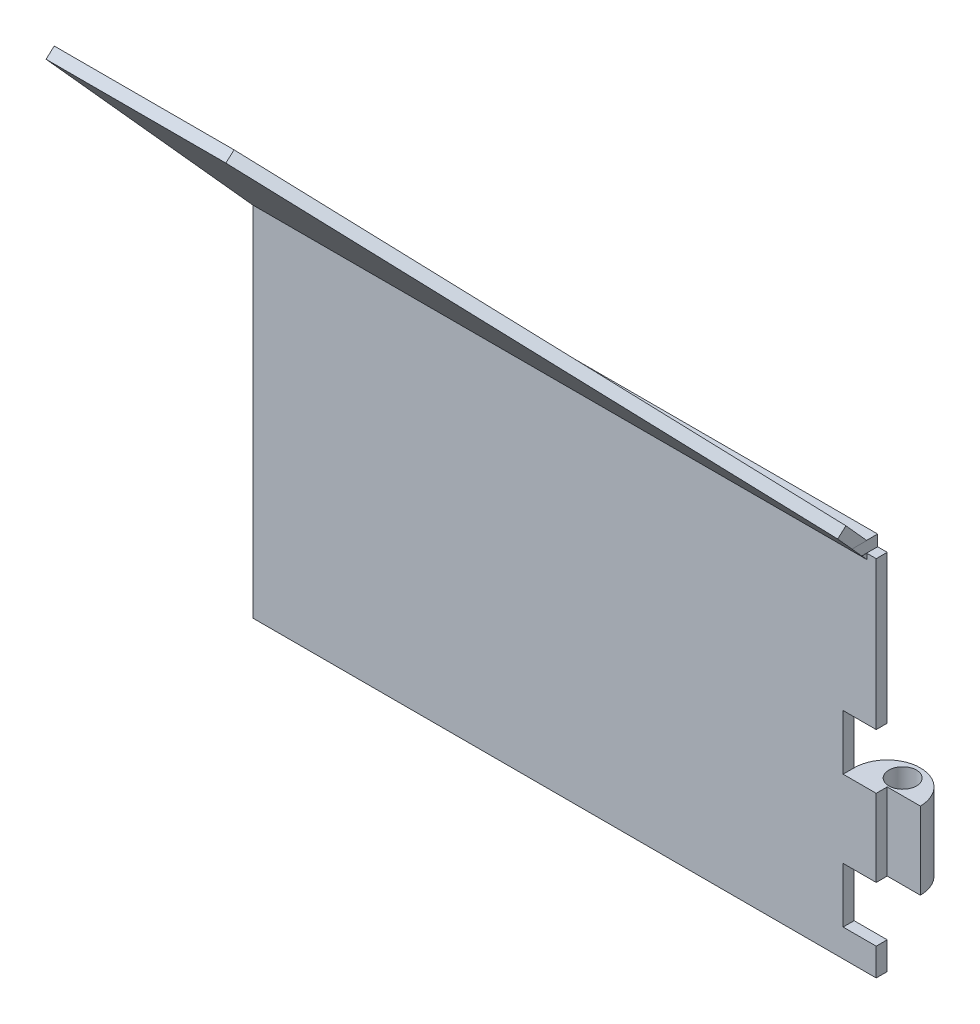
from build123d import *

# Parameters (mm, degrees)
BOSS_EXTRUDE1_DEPTH = 1
BOSS_EXTRUDE3_DEPTH = 50
BOSS_EXTRUDE6_DEPTH = 7
SKETCH8_R           = 1.25
CUT_EXTRUDE3_DEPTH  = 7
BOSS_EXTRUDE4_DEPTH = 1
SKETCH6_W           = 55.65
SKETCH6_H           = 1
BOSS_EXTRUDE5_DEPTH = 1.110613
SKETCH7_W           = 0.87
SKETCH7_H           = 1
CUT_EXTRUDE2_DEPTH  = 2.345633


with BuildPart() as part:
    # Sketch1 → Boss-Extrude1 (new body)
    with BuildSketch(Plane.XY):
        Polygon((-28.25, -16.96), (-28.25, 16.96), (28.25, 16.96), (28.25, 2.54), (25.25, 2.54), (25.25, -2.46), (28.25, -2.46), (28.25, -9.46), (25.25, -9.46), (25.25, -14.46), (28.25, -14.46), (28.25, -16.96), align=None)
    extrude(amount=BOSS_EXTRUDE1_DEPTH)

    # Sketch4 → Boss-Extrude3 (add)
    with BuildSketch(Plane.ZY.offset(28.25)):
        Polygon((0, 13.04), (-2.5, 10.54), (-2.5, -14.46), (0, -16.96), align=None)
    extrude(amount=-BOSS_EXTRUDE3_DEPTH)

    # Sketch2 → Boss-Extrude6 (add)
    with BuildSketch(Plane.XZ.offset(9.46)):
        with BuildLine():
            Line((25.25, 0), (28.25, 0))
            Line((28.25, 0), (31.25, 0))
            ThreePointArc((31.25, 0), (28.25, -3), (25.25, 0))
        make_face()
    extrude(amount=-BOSS_EXTRUDE6_DEPTH)

    # Sketch8 → Cut-Extrude3 (cut)
    with BuildSketch(Plane(origin=(0, -2.46, 0), x_dir=(1, 0, 0), z_dir=(0, 1, 0))):
        with Locations((28.25, 1.4)):
            Circle(SKETCH8_R)
    extrude(amount=-CUT_EXTRUDE3_DEPTH, mode=Mode.SUBTRACT)



with BuildPart() as body_2:
    # Sketch5 → Boss-Extrude4 (new body)
    with BuildSketch(Plane(origin=(0, 7.096337684, -7.881281441), x_dir=(-1, 0, 0), z_dir=(0, 0.669130606, -0.743144825))):
        Polygon((28.25, 13.272866846), (28.25, 40.18373624), (11.95, 40.18373624), (-27.4, 16.10373624), (-27.4, 13.272866846), align=None)
    extrude(amount=-BOSS_EXTRUDE4_DEPTH)


with BuildPart() as part_1:
    add(part.part)

    add(body_2.part)  # Boss-Extrude5 merges body 2
    # Sketch6 → Boss-Extrude5 (add)
    with BuildSketch(Plane(origin=(0, 9.863662316, 8.881281441), x_dir=(-1, 0, 0), z_dir=(0, -0.743144825, -0.669130606))):
        with Locations((0.425, 10.105310258)):
            Rectangle(SKETCH6_W, SKETCH6_H)
    extrude(amount=BOSS_EXTRUDE5_DEPTH)

    # Sketch7 → Cut-Extrude2 (cut)
    with BuildSketch(Plane.XY):
        with Locations((27.815, 16.46)):
            Rectangle(SKETCH7_W, SKETCH7_H)
    extrude(amount=CUT_EXTRUDE2_DEPTH, mode=Mode.SUBTRACT)


solid = part_1.part
